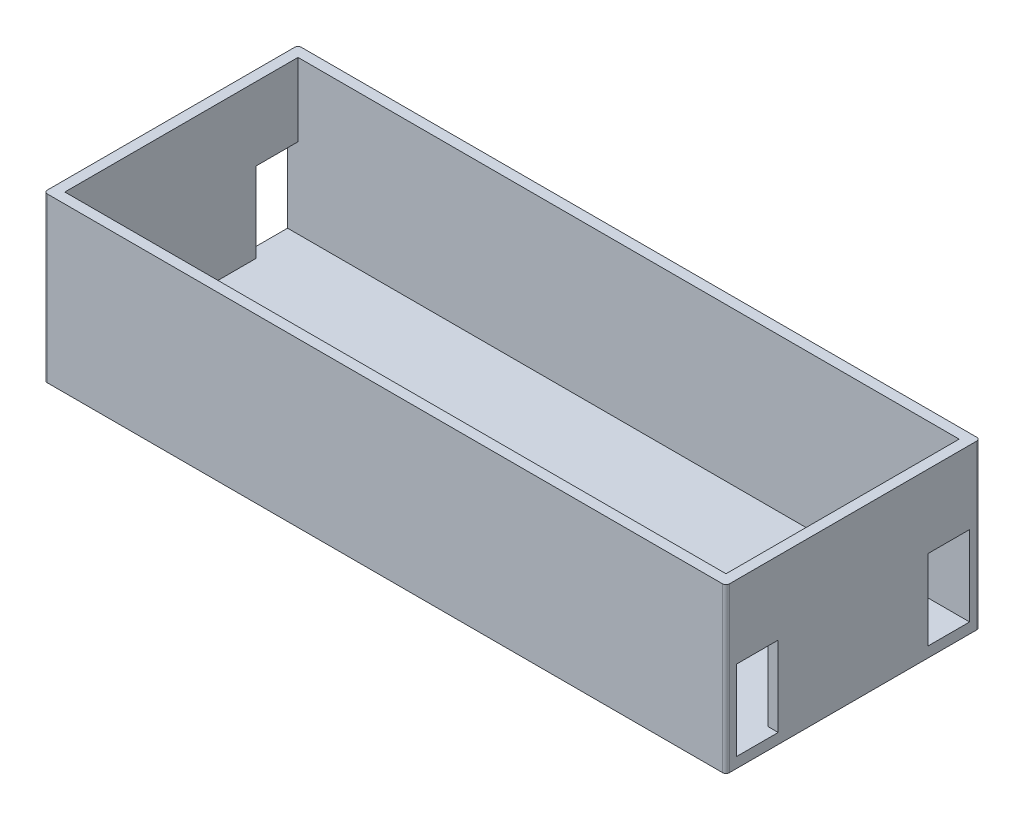
from build123d import *

# Parameters (mm, degrees)
SKETCH1_W           = 196
SKETCH1_H           = 73
BOSS_EXTRUDE1_DEPTH = 3
SKETCH3_W           = 196
SKETCH3_H           = 73
SKETCH3_W_2         = 190
SKETCH3_H_2         = 67
BOSS_EXTRUDE2_DEPTH = 44
FILLET1_R           = 1
SKETCH4_W           = 12
SKETCH4_H           = 23
CUT_EXTRUDE1_DEPTH  = 197


with BuildPart() as part:
    # Sketch1 → Boss-Extrude1 (new body)
    with BuildSketch(Plane(origin=(0, 0, 0), x_dir=(1, 0, 0), z_dir=(0, 1, 0))):
        with Locations((98, 36.5)):
            Rectangle(SKETCH1_W, SKETCH1_H)
    extrude(amount=BOSS_EXTRUDE1_DEPTH)

    # Sketch3 → Boss-Extrude2 (add)
    with BuildSketch(Plane(origin=(0, 3, 0), x_dir=(1, 0, 0), z_dir=(0, 1, 0))):
        with Locations((98, 36.5)):
            Rectangle(SKETCH3_W, SKETCH3_H)
        with Locations((98, 36.5)):
            Rectangle(SKETCH3_W_2, SKETCH3_H_2, mode=Mode.SUBTRACT)
    extrude(amount=BOSS_EXTRUDE2_DEPTH)

    # Fillet1
    fillet1_edges = [part.edges().sort_by_distance(p)[0] for p in [
        (0, 23.5, -73),
        (196, 23.5, -73),
        (196, 23.5, 0),
        (0, 23.5, 0),
    ]]
    fillet(fillet1_edges, radius=FILLET1_R)

    # Sketch4 → Cut-Extrude1 (cut, through all)
    with BuildSketch(Plane(origin=(196, 0, 0), x_dir=(0, 0, -1), z_dir=(1, 0, 0))):
        with Locations((9, 14.5)):
            Rectangle(SKETCH4_W, SKETCH4_H)
        with Locations((64, 14.5)):
            Rectangle(SKETCH4_W, SKETCH4_H)
    extrude(amount=-CUT_EXTRUDE1_DEPTH, mode=Mode.SUBTRACT)


solid = part.part
